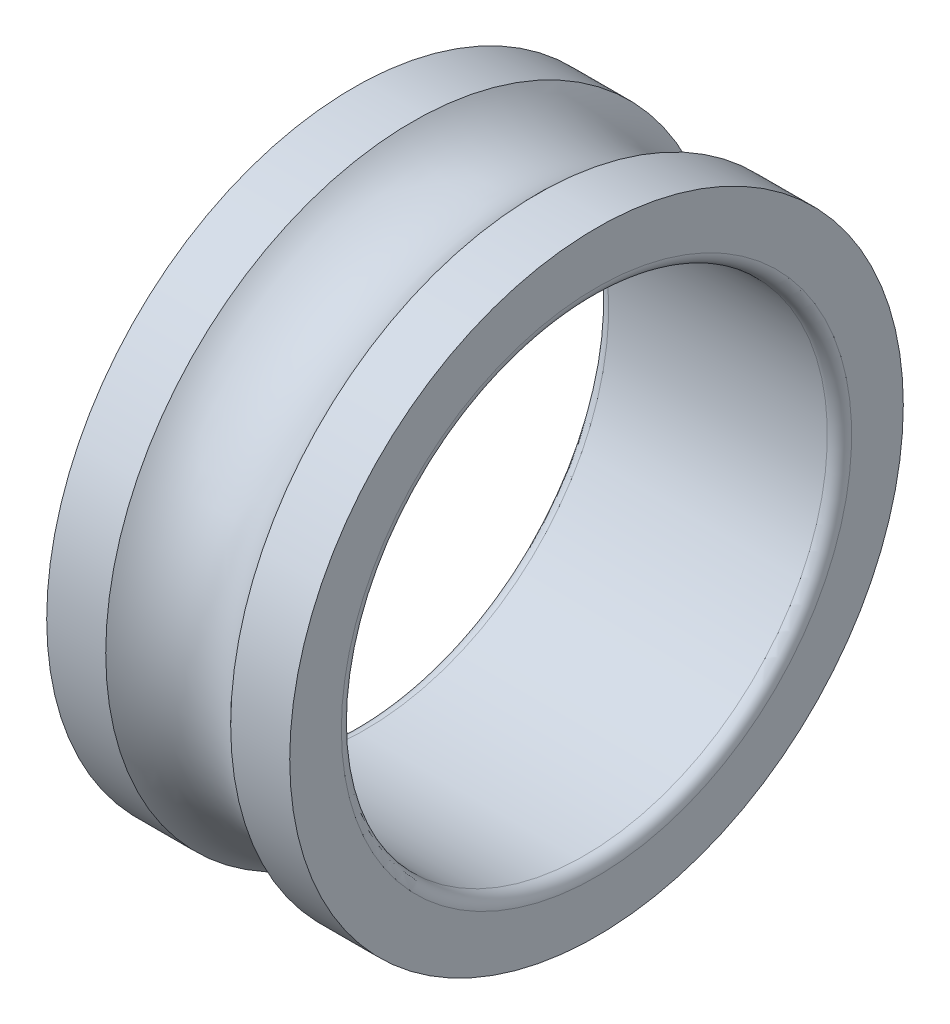
from build123d import *


with BuildPart() as part:
    # Esquisse1 → Base-Révolution (revolve)
    with BuildSketch(Plane.XY):
        with BuildLine():
            Line((0, 5.05), (0, 4.2))
            ThreePointArc((0, 4.2), (0.058578644, 4.058578644), (0.2, 4))
            Line((0.2, 4), (3.8, 4))
            ThreePointArc((3.8, 4), (3.941421356, 4.058578644), (4, 4.2))
            Line((4, 4.2), (4, 5.05))
            Line((4, 5.05), (3.02834819, 5.05))
            ThreePointArc((3.02834819, 5.05), (2, 4.6), (0.97165181, 5.05))
            Line((0.97165181, 5.05), (0, 5.05))
        make_face()
    revolve(axis=Axis((0, 0, 0), (1, 0, 0)))


solid = part.part
